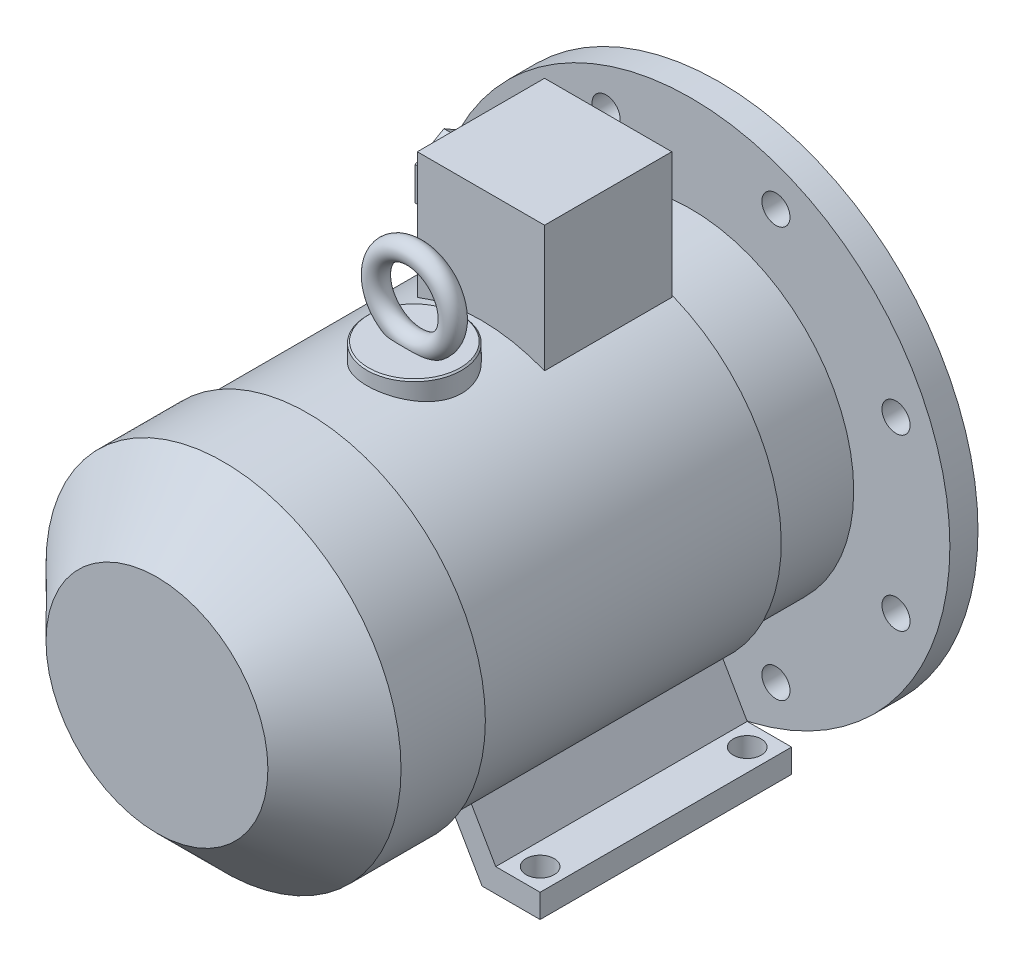
from build123d import *

# Parameters (mm, degrees)
SKETCH_1_R           = 19
EXTRUDE_1_DEPTH      = 80
SKETCH_2_W           = 8
SKETCH_2_H           = 8
EXTRUDE_2_DEPTH      = 0.1
EXTRUDE_2_DEPTH_BACK = 60
SKETCH_3_R           = 175
EXTRUDE_3_DEPTH      = 19
SKETCH_4_R           = 125
SKETCH_4_R_2         = 118
EXTRUDE_4_DEPTH      = 5
SKETCH_5_R           = 118
SKETCH_5_R_2         = 40
CUT_EXTRUDE_1_DEPTH  = 10
CHAMFER_1_SIZE       = 1
SKETCH_6_R           = 9.5
CUT_EXTRUDE_2_DEPTH  = 20
SKETCH_7_R           = 110
EXTRUDE_5_DEPTH      = 55
SKETCH_8_R           = 116
EXTRUDE_6_DEPTH      = 204
SKETCH_9_R           = 120
EXTRUDE_7_DEPTH      = 102
CHAMFER_2_SIZE       = 45
EXTRUDE_8_DEPTH      = 170
CUT_EXTRUDE_3_REACH  = 309
SKETCH_11_R          = 9.5
SKETCH_12_W          = 86
SKETCH_12_H          = 86
EXTRUDE_9_DEPTH      = 193
SKETCH_13_R          = 32
EXTRUDE_10_DEPTH     = 126
CHAMFER_3_SIZE       = 1
SKETCH_15_R          = 7
SKETCH_16_R          = 15
EXTRUDE_11_DEPTH     = 10
EXTRUDE_12_DEPTH     = 15
SKETCH_18_R          = 8
CUT_EXTRUDE_4_DEPTH  = 15


with BuildPart() as part:
    # Эскиз1 → Вытянуть1 (new body)
    with BuildSketch(Plane.XY):
        Circle(SKETCH_1_R)
    extrude(amount=EXTRUDE_1_DEPTH)

    # Эскиз2 → Вытянуть2 (add, two sides)
    with BuildSketch(Plane(origin=(0, 0, 0), x_dir=(-1, 0, 0), z_dir=(0, 0, -1))) as extrude_2_sk:
        with Locations((0, 18)):
            Rectangle(SKETCH_2_W, SKETCH_2_H)
    extrude(amount=EXTRUDE_2_DEPTH)
    extrude(extrude_2_sk.sketch, amount=-EXTRUDE_2_DEPTH_BACK)

    # Эскиз3 → Вытянуть3 (add)
    with BuildSketch(Plane.XY.offset(80)):
        Circle(SKETCH_3_R)
    extrude(amount=EXTRUDE_3_DEPTH)

    # Эскиз4 → Вытянуть4 (add)
    with BuildSketch(Plane(origin=(0, 0, 80), x_dir=(-1, 0, 0), z_dir=(0, 0, -1))):
        with Locations(Location((0, 0, 0), (0, 0, 180))):  # turned: the seam where the file's is
            Circle(SKETCH_4_R)
        Circle(SKETCH_4_R_2, mode=Mode.SUBTRACT)
    extrude(amount=EXTRUDE_4_DEPTH)

    # Эскиз5 → Вырез-Вытянуть1 (cut)
    with BuildSketch(Plane(origin=(0, 0, 80), x_dir=(-1, 0, 0), z_dir=(0, 0, -1))):
        Circle(SKETCH_5_R)
        Circle(SKETCH_5_R_2, mode=Mode.SUBTRACT)
    extrude(amount=-CUT_EXTRUDE_1_DEPTH, mode=Mode.SUBTRACT)

    # Фаска1
    chamfer_1_edges = [part.edges().sort_by_distance(p)[0] for p in [
        (-125, 0, 75),
        (40, 0, 80),
        (-11.937336386, -14.781745499, 0),
    ]]
    chamfer(chamfer_1_edges, length=CHAMFER_1_SIZE)

    # Эскиз6 → Вырез-Вытянуть2 (cut, through all)
    with BuildSketch(Plane(origin=(0, 0, 80), x_dir=(-1, 0, 0), z_dir=(0, 0, -1))):
        with Locations((-57.402514855, 138.581929877)):
            Circle(SKETCH_6_R)
        with Locations((57.402514855, 138.581929877)):
            Circle(SKETCH_6_R)
        with Locations((138.581929877, 57.402514855)):
            Circle(SKETCH_6_R)
        with Locations((138.581929877, -57.402514855)):
            Circle(SKETCH_6_R)
        with Locations((57.402514855, -138.581929877)):
            Circle(SKETCH_6_R)
        with Locations((-57.402514855, -138.581929877)):
            Circle(SKETCH_6_R)
        with Locations((-138.581929877, -57.402514855)):
            Circle(SKETCH_6_R)
        with Locations((-138.581929877, 57.402514855)):
            Circle(SKETCH_6_R)
    extrude(amount=-CUT_EXTRUDE_2_DEPTH, mode=Mode.SUBTRACT)

    # Эскиз7 → Вытянуть5 (add)
    with BuildSketch(Plane.XY.offset(99)):
        Circle(SKETCH_7_R)
    extrude(amount=EXTRUDE_5_DEPTH)

    # Эскиз8 → Вытянуть6 (add)
    with BuildSketch(Plane.XY.offset(154)):
        Circle(SKETCH_8_R)
    extrude(amount=EXTRUDE_6_DEPTH)

    # Эскиз9 → Вытянуть7 (add)
    with BuildSketch(Plane.XY.offset(358)):
        Circle(SKETCH_9_R)
    extrude(amount=EXTRUDE_7_DEPTH)

    # Фаска2
    chamfer_2_edges = [part.edges().sort_by_distance(p)[0] for p in [
        (-120, 0, 460),
    ]]
    chamfer(chamfer_2_edges, length=CHAMFER_2_SIZE)

    # Эскиз10 → Вытянуть8 (add)
    with BuildSketch(Plane(origin=(0, 0, 154), x_dir=(-1, 0, 0), z_dir=(0, 0, -1))):
        Polygon((-123, -132), (-83.762395693, -132), (-58.16412012, -87.662486121), (-72.020526581, -79.662486121), (-93, -116), (-123, -116), align=None)
        Polygon((123, -132), (83.762395693, -132), (58.16412012, -87.662486121), (72.020526581, -79.662486121), (93, -116), (123, -116), align=None)
    extrude(amount=-EXTRUDE_8_DEPTH)

    # Эскиз11 → Вырез-Вытянуть3 (cut, up to next)
    with BuildSketch(Plane.XZ.offset(132), mode=Mode.PRIVATE) as cut_extrude_3_sk1:
        with Locations((-108, 169)):
            Circle(SKETCH_11_R)
    cut_extrude_3_tool1 = extrude(cut_extrude_3_sk1.sketch, amount=-CUT_EXTRUDE_3_REACH, mode=Mode.PRIVATE) & part.part
    add(cut_extrude_3_tool1.solids().sort_by_distance((-108, -132, 169))[0], mode=Mode.SUBTRACT)
    # Эскиз11 → Вырез-Вытянуть3 (cut, up to next)
    with BuildSketch(Plane.XZ.offset(132), mode=Mode.PRIVATE) as cut_extrude_3_sk2:
        with Locations((108, 169)):
            Circle(SKETCH_11_R)
    cut_extrude_3_tool2 = extrude(cut_extrude_3_sk2.sketch, amount=-CUT_EXTRUDE_3_REACH, mode=Mode.PRIVATE) & part.part
    add(cut_extrude_3_tool2.solids().sort_by_distance((108, -132, 169))[0], mode=Mode.SUBTRACT)
    # Эскиз11 → Вырез-Вытянуть3 (cut, up to next)
    with BuildSketch(Plane.XZ.offset(132), mode=Mode.PRIVATE) as cut_extrude_3_sk3:
        with Locations((-108, 309)):
            Circle(SKETCH_11_R)
    cut_extrude_3_tool3 = extrude(cut_extrude_3_sk3.sketch, amount=-CUT_EXTRUDE_3_REACH, mode=Mode.PRIVATE) & part.part
    add(cut_extrude_3_tool3.solids().sort_by_distance((-108, -132, 309))[0], mode=Mode.SUBTRACT)
    # Эскиз11 → Вырез-Вытянуть3 (cut, up to next)
    with BuildSketch(Plane.XZ.offset(132), mode=Mode.PRIVATE) as cut_extrude_3_sk4:
        with Locations((108, 309)):
            Circle(SKETCH_11_R)
    cut_extrude_3_tool4 = extrude(cut_extrude_3_sk4.sketch, amount=-CUT_EXTRUDE_3_REACH, mode=Mode.PRIVATE) & part.part
    add(cut_extrude_3_tool4.solids().sort_by_distance((108, -132, 309))[0], mode=Mode.SUBTRACT)

    # Эскиз12 → Вытянуть9 (add)
    with BuildSketch(Plane(origin=(0, 0, 0), x_dir=(1, 0, 0), z_dir=(0, 1, 0))):
        with Locations((0, -198)):
            Rectangle(SKETCH_12_W, SKETCH_12_H)
    extrude(amount=EXTRUDE_9_DEPTH)

    # Эскиз13 → Вытянуть10 (add)
    with BuildSketch(Plane(origin=(0, 0, 0), x_dir=(1, 0, 0), z_dir=(0, 1, 0))):
        with Locations(Location((0, -286, 0), (0, 0, 90))):  # turned: the seam where the file's is
            Circle(SKETCH_13_R)
    extrude(amount=EXTRUDE_10_DEPTH)

    # Фаска3
    chamfer_3_edges = [part.edges().sort_by_distance(p)[0] for p in [
        (0, 126, 318),
    ]]
    chamfer(chamfer_3_edges, length=CHAMFER_3_SIZE)

    # По траектории1: sweep along a path in Эскиз14
    with BuildLine(Plane.XY.offset(286)) as sweep_1_path:
        CenterArc((0, 152), 26, 0, 360)
    # Эскиз15 → По траектории1 (sweep)
    with BuildSketch(Plane(origin=(0, 0, 0), x_dir=(0, 0, -1), z_dir=(1, 0, 0))):
        with Locations((-286, 178)):
            Circle(SKETCH_15_R)
    sweep(path=sweep_1_path.line)

    # Эскиз16 → Вытянуть11 (add)
    with BuildSketch(Plane.ZY.offset(43)):
        with Locations(Location((198, 150, 0), (0, 0, 180))):  # turned: the seam where the file's is
            Circle(SKETCH_16_R)
    extrude(amount=EXTRUDE_11_DEPTH)

    # Эскиз17 → Вытянуть12 (add)
    with BuildSketch(Plane.ZY.offset(53)):
        Polygon((198, 172.516660498), (178.5, 161.258330249), (178.5, 138.741669751), (198, 127.483339502), (217.5, 138.741669751), (217.5, 161.258330249), align=None)
    extrude(amount=EXTRUDE_12_DEPTH)

    # Эскиз18 → Вырез-Вытянуть4 (cut)
    with BuildSketch(Plane.ZY.offset(68)):
        with Locations((198, 150)):
            Circle(SKETCH_18_R)
    extrude(amount=-CUT_EXTRUDE_4_DEPTH, mode=Mode.SUBTRACT)


solid = part.part
